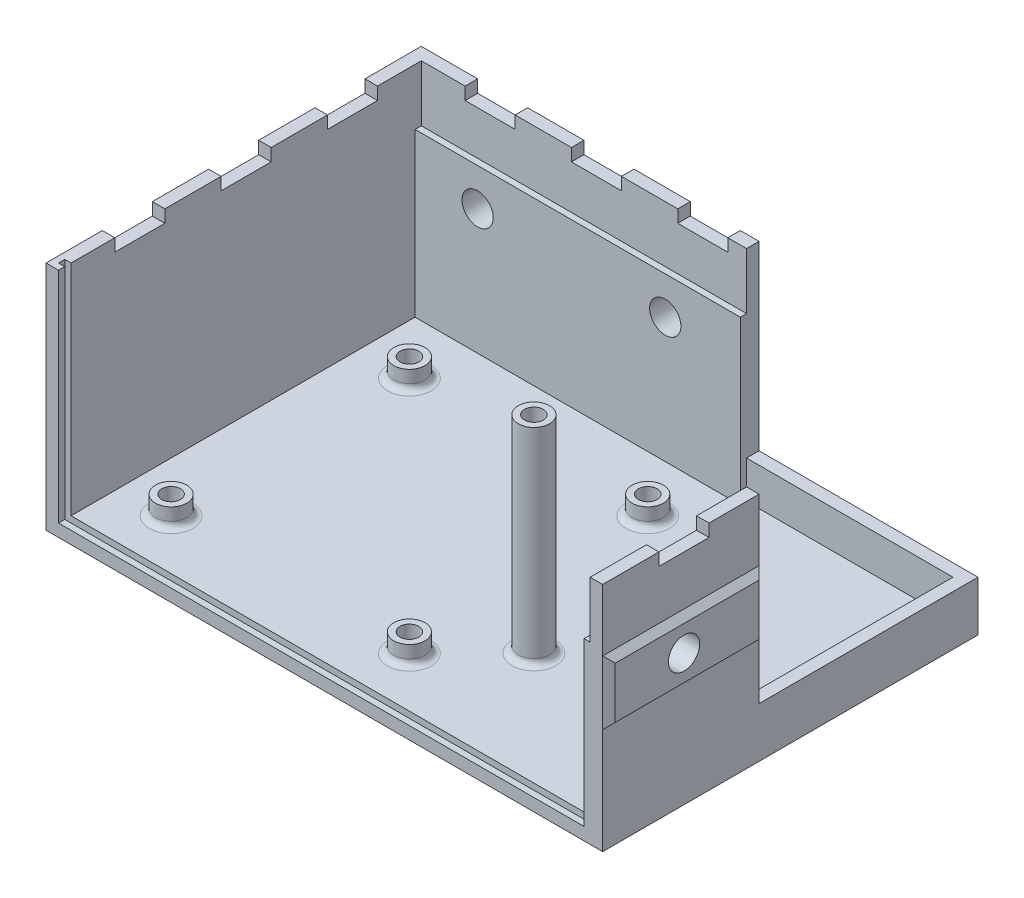
from build123d import *

# Parameters (mm, degrees)
SKETCH_483_W           = 89
SKETCH_483_H           = 60
EXTRUDE_536_DEPTH      = 2
SKETCH_586_R           = 2.5
EXTRUDE_843_DEPTH      = 3
SKETCH_888_R           = 1.5
CUT_EXTRUDE_974_DEPTH  = 6
SKETCH_1012_R          = 2.5
EXTRUDE_1193_DEPTH     = 33
SKETCH_1235_R          = 1.5
CUT_EXTRUDE_1288_DEPTH = 15
FILLET_1_R             = 1
EXTRUDE_1873_DEPTH     = 35
SKETCH_1953_W          = 35
SKETCH_1953_H          = 35
CUT_EXTRUDE_2110_DEPTH = 29
SKETCH_8_W             = 25
SKETCH_8_H             = 26
EXTRUDE_2361_DEPTH     = 1
SKETCH_2413_W          = 25
SKETCH_2413_H          = 10.2
EXTRUDE_2584_DEPTH     = 1
EXTRUDE_2584_TAPER     = 45
SKETCH_10_R            = 2.5
CUT_EXTRUDE_2826_DEPTH = 5.0000001
SKETCH_7_W             = 52
SKETCH_7_H             = 26.07500902
EXTRUDE_3066_DEPTH     = 1
SKETCH_3118_W          = 54
SKETCH_3118_H          = 10.2
EXTRUDE_3289_DEPTH     = 1
EXTRUDE_3289_TAPER     = 45
SKETCH_3351_R          = 2.5
CUT_EXTRUDE_3526_DEPTH = 5.0000001
SKETCH_3564_W          = 84
SKETCH_3564_H          = 1
CUT_EXTRUDE_3883_DEPTH = 1
SKETCH_3943_W          = 1
SKETCH_3943_H          = 36
CUT_EXTRUDE_4171_DEPTH = 1
SKETCH_4235_W          = 1
SKETCH_4235_H          = 27
CUT_EXTRUDE_4453_DEPTH = 1
SKETCH_26_W            = 2
SKETCH_26_H            = 8
CUT_EXTRUDE_4670_DEPTH = 2
SKETCH_4730_W          = 2
SKETCH_4730_H          = 8
SKETCH_4730_W_2        = 8
SKETCH_4730_H_2        = 2
CUT_EXTRUDE_5100_DEPTH = 2


with BuildPart() as part:
    # Sketch 483 → Extrude 536 (new body)
    with BuildSketch(Plane(origin=(0, 0, 0), x_dir=(1, 0, 0), z_dir=(0, 1, 0))):
        with Locations((44.5, 30)):
            Rectangle(SKETCH_483_W, SKETCH_483_H)
    extrude(amount=EXTRUDE_536_DEPTH)

    # Sketch 586 → Extrude 843 (add)
    with BuildSketch(Plane(origin=(0, 2, 0), x_dir=(1, 0, 0), z_dir=(0, 1, 0))):
        with Locations((10, 10)):
            Circle(SKETCH_586_R)
        with Locations((48.1, 10)):
            Circle(SKETCH_586_R)
        with Locations((48.1, 48.1)):
            Circle(SKETCH_586_R)
        with Locations((10, 48.1)):
            Circle(SKETCH_586_R)
    extrude(amount=EXTRUDE_843_DEPTH)

    # Sketch 888 → Cut-Extrude 974 (cut, through all)
    with BuildSketch(Plane(origin=(0, 5, 0), x_dir=(1, 0, 0), z_dir=(0, 1, 0))):
        with Locations((48.1, 10)):
            Circle(SKETCH_888_R)
        with Locations((10, 10)):
            Circle(SKETCH_888_R)
        with Locations((10, 48.1)):
            Circle(SKETCH_888_R)
        with Locations((48.1, 48.1)):
            Circle(SKETCH_888_R)
    extrude(amount=-CUT_EXTRUDE_974_DEPTH, mode=Mode.SUBTRACT)

    # Sketch 1012 → Extrude 1193 (add)
    with BuildSketch(Plane(origin=(0, 2, 0), x_dir=(1, 0, 0), z_dir=(0, 1, 0))):
        with Locations((58, 20)):
            Circle(SKETCH_1012_R)
    extrude(amount=EXTRUDE_1193_DEPTH)

    # Sketch 1235 → Cut-Extrude 1288 (cut)
    with BuildSketch(Plane(origin=(0, 35, 0), x_dir=(1, 0, 0), z_dir=(0, 1, 0))):
        with Locations((58, 20)):
            Circle(SKETCH_1235_R)
    extrude(amount=-CUT_EXTRUDE_1288_DEPTH, mode=Mode.SUBTRACT)

    # 圆角1
    fillet_1_edges = [part.edges().sort_by_distance(p)[0] for p in [
        (7.5, 2, -10),
        (45.6, 2, -10),
        (45.6, 2, -48.1),
        (7.5, 2, -48.1),
        (55.5, 2, -20),
    ]]
    fillet(fillet_1_edges, radius=FILLET_1_R)

    # Sketch 1575 → Extrude 1873 (add)
    with BuildSketch(Plane(origin=(0, 2, 0), x_dir=(1, 0, 0), z_dir=(0, 1, 0))):
        Polygon((87, 0), (87, 58), (2, 58), (2, 0), (0, 0), (0, 60), (89, 60), (89, 0), align=None)
    extrude(amount=EXTRUDE_1873_DEPTH)

    # Sketch 1953 → Cut-Extrude 2110 (cut)
    with BuildSketch(Plane(origin=(0, 37, 0), x_dir=(1, 0, 0), z_dir=(0, 1, 0))):
        with Locations((71.5, 42.5)):
            Rectangle(SKETCH_1953_W, SKETCH_1953_H)
    extrude(amount=-CUT_EXTRUDE_2110_DEPTH, mode=Mode.SUBTRACT)

    # 草图8 → Extrude 2361 (add)
    with BuildSketch(Plane.ZY.offset(-87)):
        with Locations((-12.5, 15)):
            Rectangle(SKETCH_8_W, SKETCH_8_H)
    extrude(amount=EXTRUDE_2361_DEPTH)

    # Sketch 2413 → Extrude 2584 (add)
    with BuildSketch(Plane(origin=(89, 0, 0), x_dir=(0, 0, -1), z_dir=(1, 0, 0))):
        with Locations((12.5, 22)):
            Rectangle(SKETCH_2413_W, SKETCH_2413_H)
    extrude(amount=EXTRUDE_2584_DEPTH, taper=EXTRUDE_2584_TAPER)

    # 草图10 → Cut-Extrude 2826 (cut, through all)
    with BuildSketch(Plane.ZY.offset(-86)):
        with Locations((-12, 22)):
            Circle(SKETCH_10_R)
    extrude(amount=-CUT_EXTRUDE_2826_DEPTH, mode=Mode.SUBTRACT)

    # 草图7 → Extrude 3066 (add)
    with BuildSketch(Plane.XY.offset(-58)):
        with Locations((28, 14.96249549)):
            Rectangle(SKETCH_7_W, SKETCH_7_H)
    extrude(amount=EXTRUDE_3066_DEPTH)

    # Sketch 3118 → Extrude 3289 (add)
    with BuildSketch(Plane(origin=(0, 0, -60), x_dir=(-1, 0, 0), z_dir=(0, 0, -1))):
        with Locations((-27, 22)):
            Rectangle(SKETCH_3118_W, SKETCH_3118_H)
    extrude(amount=EXTRUDE_3289_DEPTH, taper=EXTRUDE_3289_TAPER)

    # Sketch 3351 → Cut-Extrude 3526 (cut, through all)
    with BuildSketch(Plane.XY.offset(-57)):
        with Locations((12, 22)):
            Circle(SKETCH_3351_R)
        with Locations((42, 22)):
            Circle(SKETCH_3351_R)
    extrude(amount=-CUT_EXTRUDE_3526_DEPTH, mode=Mode.SUBTRACT)

    # Sketch 3564 → Cut-Extrude 3883 (cut)
    with BuildSketch(Plane(origin=(0, 2, 0), x_dir=(1, 0, 0), z_dir=(0, 1, 0))):
        with Locations((44, 1.5)):
            Rectangle(SKETCH_3564_W, SKETCH_3564_H)
    extrude(amount=-CUT_EXTRUDE_3883_DEPTH, mode=Mode.SUBTRACT)

    # Sketch 3943 → Cut-Extrude 4171 (cut)
    with BuildSketch(Plane(origin=(2, 0, 0), x_dir=(0, 0, -1), z_dir=(1, 0, 0))):
        with Locations((1.5, 19)):
            Rectangle(SKETCH_3943_W, SKETCH_3943_H)
    extrude(amount=-CUT_EXTRUDE_4171_DEPTH, mode=Mode.SUBTRACT)

    # Sketch 4235 → Cut-Extrude 4453 (cut)
    with BuildSketch(Plane.ZY.offset(-86)):
        with Locations((-1.5, 14.5)):
            Rectangle(SKETCH_4235_W, SKETCH_4235_H)
    extrude(amount=-CUT_EXTRUDE_4453_DEPTH, mode=Mode.SUBTRACT)

    # 草图26 → Cut-Extrude 4670 (cut)
    with BuildSketch(Plane(origin=(0, 37, 0), x_dir=(1, 0, 0), z_dir=(0, 1, 0))):
        with Locations((88, 13)):
            Rectangle(SKETCH_26_W, SKETCH_26_H)
    extrude(amount=-CUT_EXTRUDE_4670_DEPTH, mode=Mode.SUBTRACT)

    # Sketch 4730 → Cut-Extrude 5100 (cut)
    with BuildSketch(Plane(origin=(0, 37, 0), x_dir=(1, 0, 0), z_dir=(0, 1, 0))):
        with Locations((1, 13)):
            Rectangle(SKETCH_4730_W, SKETCH_4730_H)
        with Locations((1, 30)):
            Rectangle(SKETCH_4730_W, SKETCH_4730_H)
        with Locations((1, 47)):
            Rectangle(SKETCH_4730_W, SKETCH_4730_H)
        with Locations((13, 59)):
            Rectangle(SKETCH_4730_W_2, SKETCH_4730_H_2)
        with Locations((30, 59)):
            Rectangle(SKETCH_4730_W_2, SKETCH_4730_H_2)
        with Locations((47, 59)):
            Rectangle(SKETCH_4730_W_2, SKETCH_4730_H_2)
    extrude(amount=-CUT_EXTRUDE_5100_DEPTH, mode=Mode.SUBTRACT)


solid = part.part
